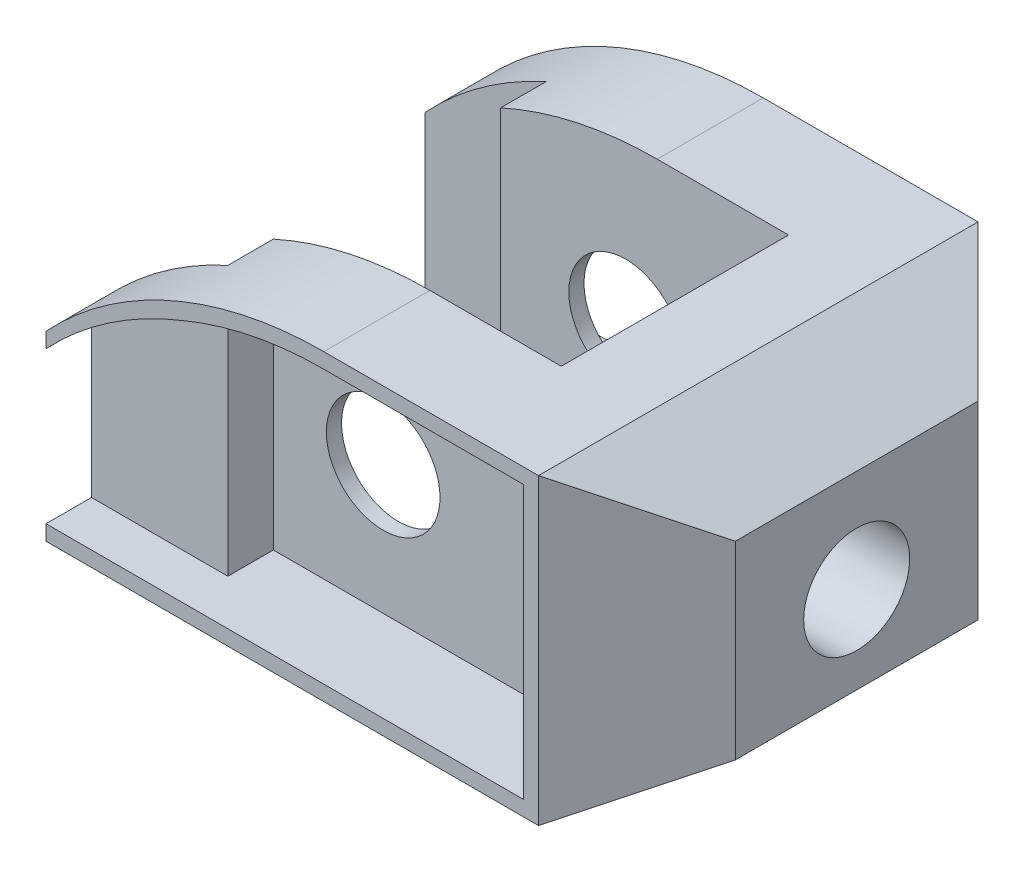
from build123d import *

# Parameters (mm, degrees)
SKETCH1_R               = 7.5
BOSS_EXTRUDE1_DEPTH     = 58
SKETCH2_W               = 38
SKETCH2_H               = 30
CUT_EXTRUDE1_DEPTH      = 84.865217872
CUT_EXTRUDE1_DEPTH_BACK = 84.865217872
SKETCH3_W               = 16
SKETCH3_H               = 6
CUT_EXTRUDE4_DEPTH      = 84.865217872
CUT_EXTRUDE4_DEPTH_BACK = 84.865217872
SKETCH4_R               = 7
CUT_EXTRUDE5_DEPTH      = 100.435906681
CUT_EXTRUDE5_DEPTH_BACK = 100.435906681
CUT_EXTRUDE6_DEPTH      = 84.865217872
CUT_EXTRUDE6_DEPTH_BACK = 84.865217872
SKETCH9_R               = 7.5
CUT_EXTRUDE10_DEPTH     = 12
CUT_EXTRUDE12_DEPTH     = 6
CUT_EXTRUDE13_DEPTH     = 12
CUT_EXTRUDE14_DEPTH     = 6


with BuildPart() as part:
    # Sketch1 → Boss-Extrude1 (new body)
    with BuildSketch(Plane.XY):
        with BuildLine():
            Line((32.5, -19), (-32.5, -19))
            Line((-32.5, -19), (-32.5, 5))
            ThreePointArc((-32.5, 5), (-15.83939444, 16.82575695), (4.16060556, 21))
            Line((4.16060556, 21), (32.5, 21))
            Line((32.5, 21), (45.490381057, 13.5))
            Line((45.490381057, 13.5), (45.490381057, -11.5))
            Line((45.490381057, -11.5), (32.5, -19))
        make_face()
        with Locations(Location((0, 0, 0), (0, 0, 180))):
            Circle(SKETCH1_R, mode=Mode.SUBTRACT)
    extrude(amount=BOSS_EXTRUDE1_DEPTH)

    # Sketch2 → Cut-Extrude1 (cut, two sides)
    with BuildSketch(Plane(origin=(0, 21, 0), x_dir=(1, 0, 0), z_dir=(0, 1, 0))) as cut_extrude1_sk:
        with Locations((2.5, -29)):
            Rectangle(SKETCH2_W, SKETCH2_H)
    extrude(amount=CUT_EXTRUDE1_DEPTH, mode=Mode.SUBTRACT)
    extrude(cut_extrude1_sk.sketch, amount=-CUT_EXTRUDE1_DEPTH_BACK, mode=Mode.SUBTRACT)

    # Sketch3 → Cut-Extrude4 (cut, two sides)
    with BuildSketch(Plane(origin=(0, 21, 0), x_dir=(1, 0, 0), z_dir=(0, 1, 0))) as cut_extrude4_sk:
        with Locations((-24.5, -47)):
            Rectangle(SKETCH3_W, SKETCH3_H)
        with Locations((-24.5, -11)):
            Rectangle(SKETCH3_W, SKETCH3_H)
    extrude(amount=CUT_EXTRUDE4_DEPTH, mode=Mode.SUBTRACT)
    extrude(cut_extrude4_sk.sketch, amount=-CUT_EXTRUDE4_DEPTH_BACK, mode=Mode.SUBTRACT)


with BuildPart() as body_2:
    # of the pieces the cut leaves, the one that is kept (cut_extrude4_keep)
    add(part.part.solids().sort_by_distance((4.16060556, 21, 0))[0])

    # Sketch4 → Cut-Extrude5 (cut, two sides)
    with BuildSketch(Plane(origin=(45.490381057, 0, 0), x_dir=(0, 0, -1), z_dir=(1, 0, 0))) as cut_extrude5_sk:
        with Locations(Location((-29, 0, 0), (0, 0, 90))):
            Circle(SKETCH4_R)
    extrude(amount=CUT_EXTRUDE5_DEPTH, mode=Mode.SUBTRACT)
    extrude(cut_extrude5_sk.sketch, amount=-CUT_EXTRUDE5_DEPTH_BACK, mode=Mode.SUBTRACT)

    # Sketch6 → Cut-Extrude6 (cut, two sides)
    with BuildSketch(Plane(origin=(0, 21, 0), x_dir=(1, 0, 0), z_dir=(0, 1, 0))) as cut_extrude6_sk:
        Polygon((32.5, 0), (45.490381057, -12.990381057), (45.490381057, 0), align=None)
        Polygon((45.490381057, -45.009618943), (45.490381057, -58), (32.5, -58), align=None)
    extrude(amount=CUT_EXTRUDE6_DEPTH, mode=Mode.SUBTRACT)
    extrude(cut_extrude6_sk.sketch, amount=-CUT_EXTRUDE6_DEPTH_BACK, mode=Mode.SUBTRACT)

    # Sketch9 → Cut-Extrude10 (cut)
    with BuildSketch(Plane.XY.offset(58)):
        with BuildLine():
            Line((30.5, 19), (4.16060556, 19))
            ThreePointArc((4.16060556, 19), (-5.358778616, 18.046586751), (-14.5, 15.224221872))
            Line((-14.5, 15.224221872), (-14.5, -17))
            Line((-14.5, -17), (30.5, -17))
            Line((30.5, -17), (30.5, 19))
        make_face()
        with Locations(Location((0, 0, 0), (0, 0, 180))):
            Circle(SKETCH9_R, mode=Mode.SUBTRACT)
    extrude(amount=-CUT_EXTRUDE10_DEPTH, mode=Mode.SUBTRACT)

    # Sketch10 → Cut-Extrude12 (cut)
    with BuildSketch(Plane.XY.offset(58)):
        with BuildLine():
            Line((-14.5, 15.224221872), (-14.5, -17))
            Line((-14.5, -17), (-32.5, -17))
            Line((-32.5, -17), (-32.5, 3))
            ThreePointArc((-32.5, 3), (-24.178137204, 10.110658721), (-14.5, 15.224221872))
        make_face()
    extrude(amount=-CUT_EXTRUDE12_DEPTH, mode=Mode.SUBTRACT)

    # Sketch14 → Cut-Extrude13 (cut)
    with BuildSketch(Plane(origin=(0, 0, 0), x_dir=(-1, 0, 0), z_dir=(0, 0, -1))):
        with BuildLine():
            Line((14.5, -17), (14.5, 15.224221872))
            ThreePointArc((14.5, 15.224221872), (5.358778616, 18.046586751), (-4.16060556, 19))
            Line((-4.16060556, 19), (-30.5, 19))
            Line((-30.5, 19), (-30.5, -17))
            Line((-30.5, -17), (14.5, -17))
        make_face()
    extrude(amount=-CUT_EXTRUDE13_DEPTH, mode=Mode.SUBTRACT)

    # Sketch15 → Cut-Extrude14 (cut)
    with BuildSketch(Plane(origin=(0, 0, 0), x_dir=(-1, 0, 0), z_dir=(0, 0, -1))):
        with BuildLine():
            Line((14.5, 15.224221872), (14.5, -17))
            Line((14.5, -17), (32.5, -17))
            Line((32.5, -17), (32.5, 1.972887098))
            ThreePointArc((32.5, 1.972887098), (24.250830172, 9.618447449), (14.5, 15.224221872))
        make_face()
    extrude(amount=-CUT_EXTRUDE14_DEPTH, mode=Mode.SUBTRACT)


solid = body_2.part
